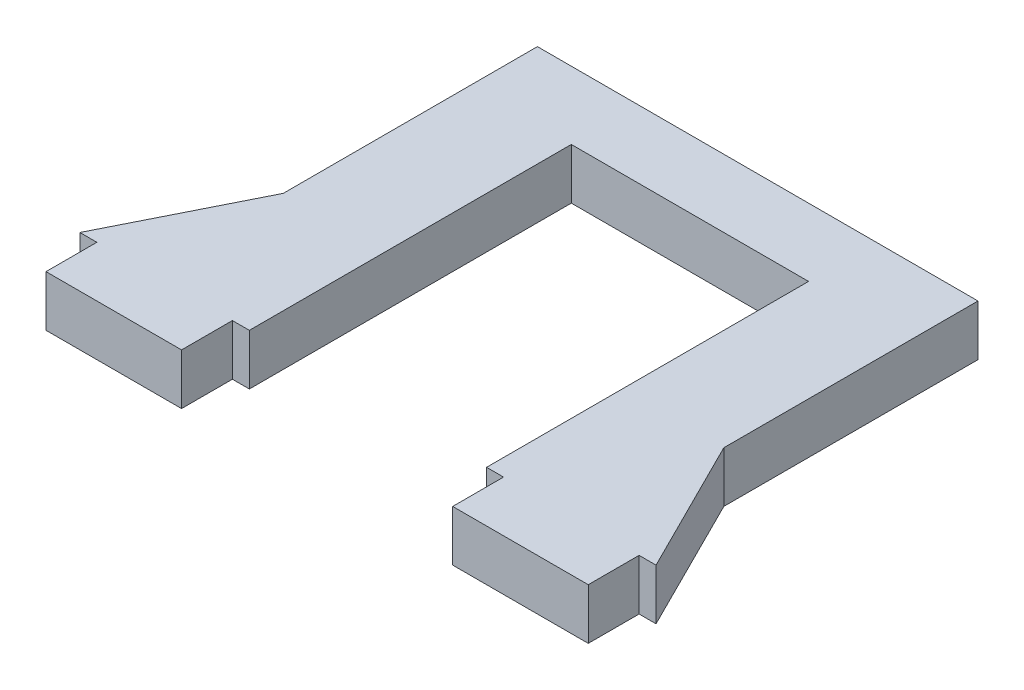
from build123d import *

# Parameters (mm, degrees)
BOSS_EXTRUDE1_DEPTH = 1.5
BOSS_EXTRUDE2_DEPTH = 1.5
SKETCH3_W           = 8
SKETCH3_H           = 3
BOSS_EXTRUDE3_DEPTH = 1.5


with BuildPart() as part:
    # Sketch1 → Boss-Extrude1 (new body, symmetric)
    with BuildSketch(Plane(origin=(0, 0, 0), x_dir=(1, 0, 0), z_dir=(0, 1, 0))):
        Polygon((7, -9.5), (13, -9.5), (13, 13.5), (-13, 13.5), (-13, -9.5), (-7, -9.5), (-7, 9.5), (7, 9.5), align=None)
    extrude(amount=BOSS_EXTRUDE1_DEPTH, both=True)

    # Sketch2 → Boss-Extrude2 (add, symmetric)
    with BuildSketch(Plane(origin=(0, 0, 0), x_dir=(1, 0, 0), z_dir=(0, 1, 0))):
        Polygon((-13, -1.5), (-17, -9.5), (-13, -9.5), align=None)
        Polygon((13, -9.5), (13, -1.5), (17, -9.5), align=None)
    extrude(amount=BOSS_EXTRUDE2_DEPTH, both=True)

    # Sketch3 → Boss-Extrude3 (add, symmetric)
    with BuildSketch(Plane(origin=(0, 0, 0), x_dir=(1, 0, 0), z_dir=(0, 1, 0))):
        with Locations((-12, -11)):
            Rectangle(SKETCH3_W, SKETCH3_H)
        with Locations((12, -11)):
            Rectangle(SKETCH3_W, SKETCH3_H)
    extrude(amount=BOSS_EXTRUDE3_DEPTH, both=True)


solid = part.part
